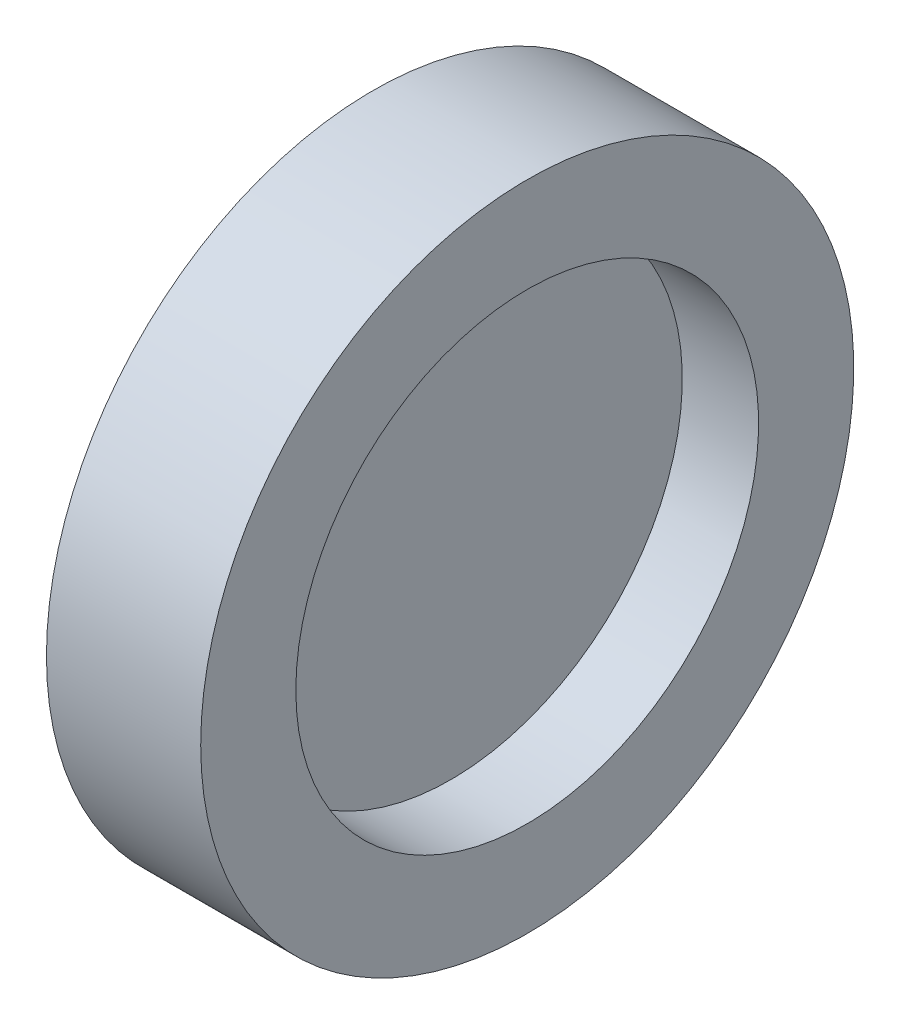
from build123d import *

# Parameters (mm, degrees)
SKETCH_1_W = 0.061
SKETCH_1_H = 9
SKETCH_4_W = 6
SKETCH_4_H = 3.7


with BuildPart() as part:
    # 草图1 → 旋转2 (revolve)
    with BuildSketch(Plane.XY, mode=Mode.PRIVATE) as revolve_2_sk:
        with Locations((0, 4.5)):
            Rectangle(SKETCH_1_W, SKETCH_1_H)
    revolve(revolve_2_sk.sketch.rotate(Axis((-0.0305, 0, 0), (1, 0, 0)), 90), axis=Axis((-0.0305, 0, 0), (1, 0, 0)))  # turned: the seam where the file's is

    # 草图4 → 旋转3 (revolve)
    with BuildSketch(Plane.XY, mode=Mode.PRIVATE) as revolve_3_sk:
        with Locations((0, 10.85)):
            Rectangle(SKETCH_4_W, SKETCH_4_H)
    revolve(revolve_3_sk.sketch.rotate(Axis((-1.614212419, 0, 0), (1, 0, 0)), 90), axis=Axis((-1.614212419, 0, 0), (1, 0, 0)))  # turned: the seam where the file's is


solid = part.part
